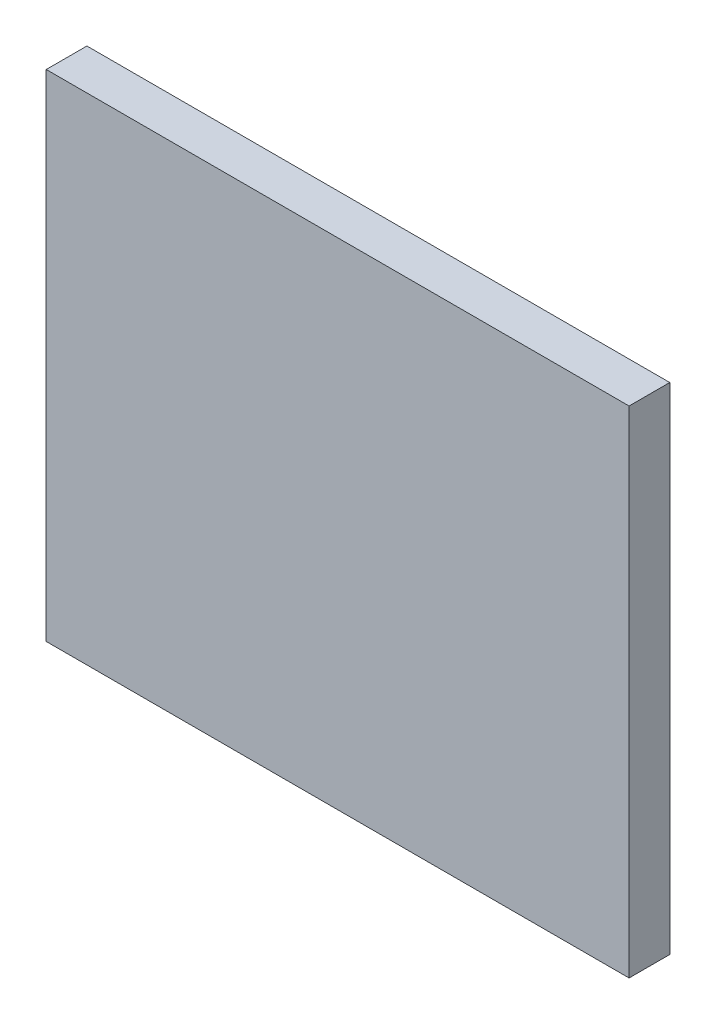
from build123d import *

# Parameters (mm, degrees)
ESBO_O1_W                = 39.98
ESBO_O1_H                = 33.98
RESSALTO_EXTRUS_O1_DEPTH = 2.79


with BuildPart() as part:
    # Esboço1 → Ressalto-extrusão1 (new body)
    with BuildSketch(Plane.XY):
        with Locations((19.99, 16.99)):
            Rectangle(ESBO_O1_W, ESBO_O1_H)
    extrude(amount=RESSALTO_EXTRUS_O1_DEPTH)


solid = part.part
